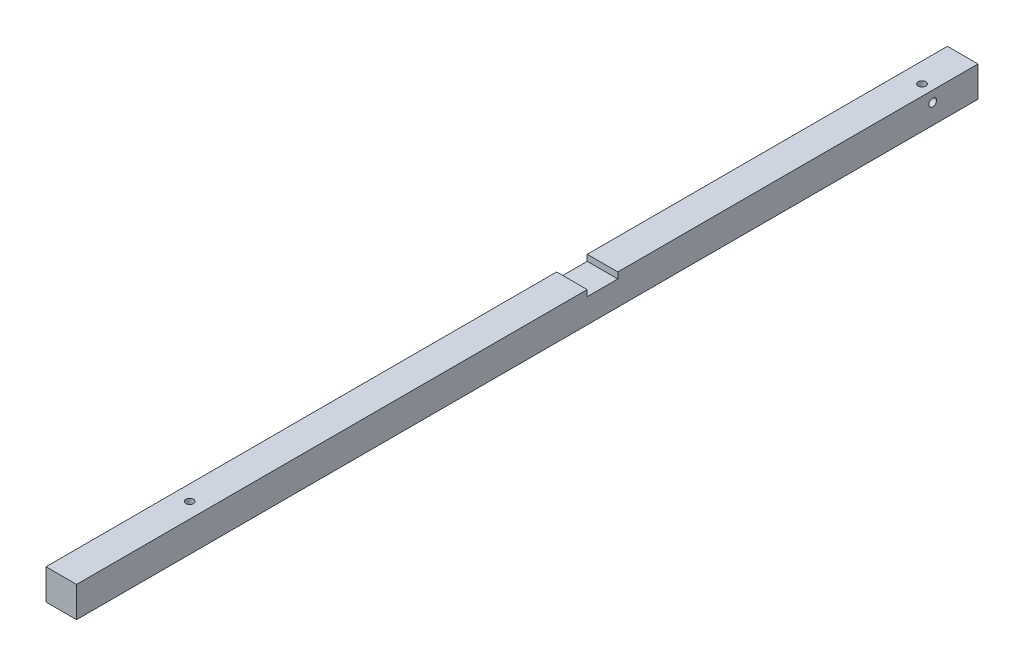
from build123d import *

# Parameters (mm, degrees)
ESQUISSE1_W                     = 10
ESQUISSE1_H                     = 10
BOSS_EXTRU_1_DEPTH              = 294.8
TROU_TARAUD_M3X0_51_D           = 2.5
TROU_TARAUD_M3X0_51_DEPTH       = 8.5
TROU_TARAUD_M3X0_51_CSINK_D     = 3.05
TROU_TARAUD_M3X0_51_CSINK_ANGLE = 90
TROU_TARAUD_M3X0_51_TIP         = 0.751075774
ESQUISSE4_W                     = 10
ESQUISSE4_H                     = 2
ENL_V_MAT_EXTRU_1_DEPTH         = 11
TROU_TARAUD_M3X0_52_D           = 2.5
TROU_TARAUD_M3X0_52_CSINK_D     = 3.05
TROU_TARAUD_M3X0_52_CSINK_ANGLE = 90
TROU_TARAUD_M3X0_53_D           = 2.5
TROU_TARAUD_M3X0_53_CSINK_D     = 3.05
TROU_TARAUD_M3X0_53_CSINK_ANGLE = 90
TROU_TARAUD_M3X0_54_D           = 2.5
TROU_TARAUD_M3X0_54_CSINK_D     = 3.05
TROU_TARAUD_M3X0_54_CSINK_ANGLE = 90


with BuildPart() as part:
    # Esquisse1 → Boss.-Extru.1 (new body)
    with BuildSketch(Plane.XY):
        Rectangle(ESQUISSE1_W, ESQUISSE1_H)
    extrude(amount=BOSS_EXTRU_1_DEPTH)

    # Trou taraudé M3x0.51
    with Locations(Plane(origin=(0, 0, 0), x_dir=(-1, 0, 0), z_dir=(0, 0, -1))):
        with Locations((0, 0)):
            CounterSinkHole(TROU_TARAUD_M3X0_51_D / 2, TROU_TARAUD_M3X0_51_CSINK_D / 2, depth=TROU_TARAUD_M3X0_51_DEPTH, counter_sink_angle=TROU_TARAUD_M3X0_51_CSINK_ANGLE)
            with Locations((0, 0, -(TROU_TARAUD_M3X0_51_DEPTH + TROU_TARAUD_M3X0_51_TIP / 2))):  # 118° drill point
                Cone(0, TROU_TARAUD_M3X0_51_D / 2, TROU_TARAUD_M3X0_51_TIP, mode=Mode.SUBTRACT)

    # Esquisse4 → Enlèv. mat.-Extru.1 (cut, through all)
    with BuildSketch(Plane.ZY.offset(5)):
        with Locations((122.8, 4)):
            Rectangle(ESQUISSE4_W, ESQUISSE4_H)
    extrude(amount=-ENL_V_MAT_EXTRU_1_DEPTH, mode=Mode.SUBTRACT)

    # Trou taraudé M3x0.52 (through all)
    with Locations(Plane(origin=(0, -5, 0), x_dir=(-1, 0, 0), z_dir=(0, -1, 0))):
        with Locations((-1.5, -14.8)):
            CounterSinkHole(TROU_TARAUD_M3X0_52_D / 2, TROU_TARAUD_M3X0_52_CSINK_D / 2, counter_sink_angle=TROU_TARAUD_M3X0_52_CSINK_ANGLE)

    # Trou taraudé M3x0.53 (through all)
    with Locations(Plane.ZY.offset(5)):
        with Locations((14.8, 1.5)):
            CounterSinkHole(TROU_TARAUD_M3X0_53_D / 2, TROU_TARAUD_M3X0_53_CSINK_D / 2, counter_sink_angle=TROU_TARAUD_M3X0_53_CSINK_ANGLE)

    # Trou taraudé M3x0.54 (through all)
    with Locations(Plane(origin=(0, -5, 0), x_dir=(-1, 0, 0), z_dir=(0, -1, 0))):
        with Locations((0, -252.8)):
            CounterSinkHole(TROU_TARAUD_M3X0_54_D / 2, TROU_TARAUD_M3X0_54_CSINK_D / 2, counter_sink_angle=TROU_TARAUD_M3X0_54_CSINK_ANGLE)


solid = part.part
